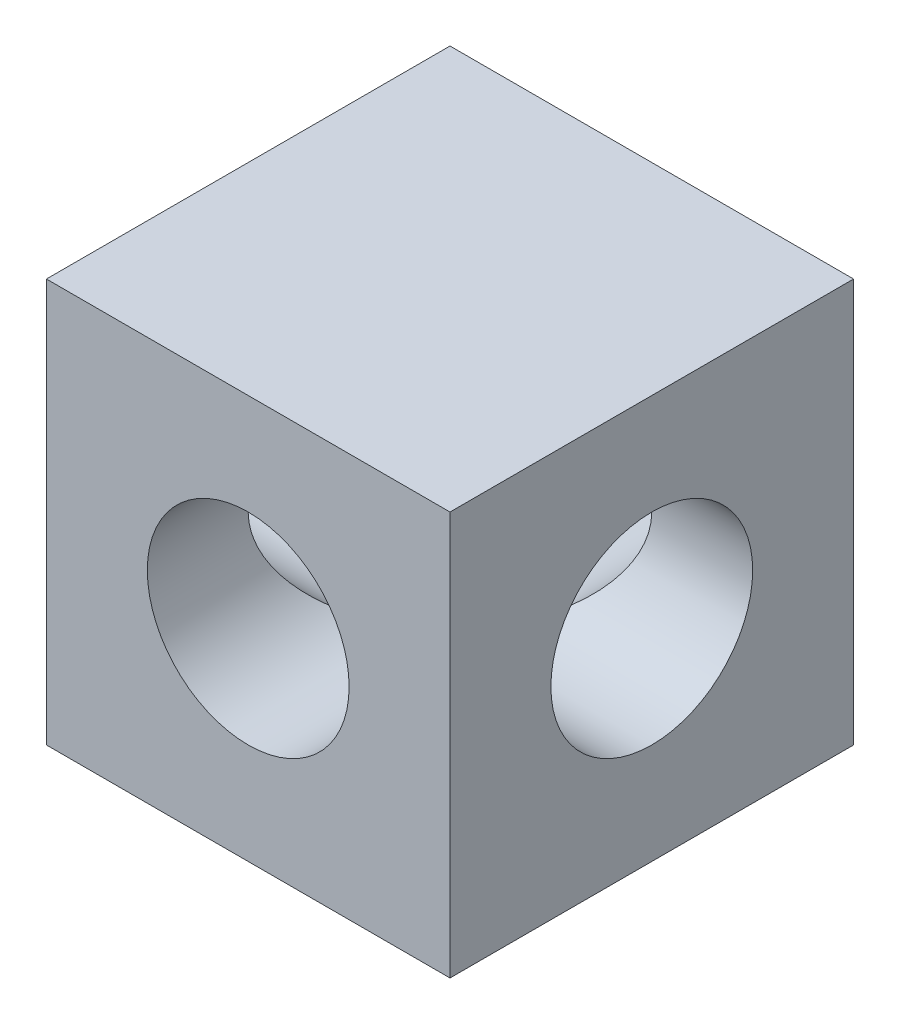
from build123d import *

# Parameters (mm, degrees)
SKETCH1_W          = 19.05
SKETCH1_H          = 19.05
SKETCH1_R          = 4.7625
BASE_EXTRUDE_DEPTH = 9.525
SKETCH3_R          = 4.7625
CUT_EXTRUDE1_DEPTH = 24.3313898
SCALE1_SCALE       = 0.8


with BuildPart() as part:
    # Sketch1 → Base-Extrude (new, symmetric)
    with BuildSketch(Plane.XY):
        Rectangle(SKETCH1_W, SKETCH1_H)
        with Locations(Location((0, 0, 0), (0, 0, 180))):
            Circle(SKETCH1_R, mode=Mode.SUBTRACT)
    extrude(amount=BASE_EXTRUDE_DEPTH, both=True)

    # Sketch3 → Cut-Extrude1 (cut, through all)
    with BuildSketch(Plane(origin=(9.525, 0, 0), x_dir=(0, 0, -1), z_dir=(1, 0, 0))):
        Circle(SKETCH3_R)
    extrude(amount=-CUT_EXTRUDE1_DEPTH, mode=Mode.SUBTRACT)


with BuildPart() as part_1:
    # Scale1: scaled about (0, 0, 0)
    add(part.part.scale(SCALE1_SCALE))


solid = part_1.part
